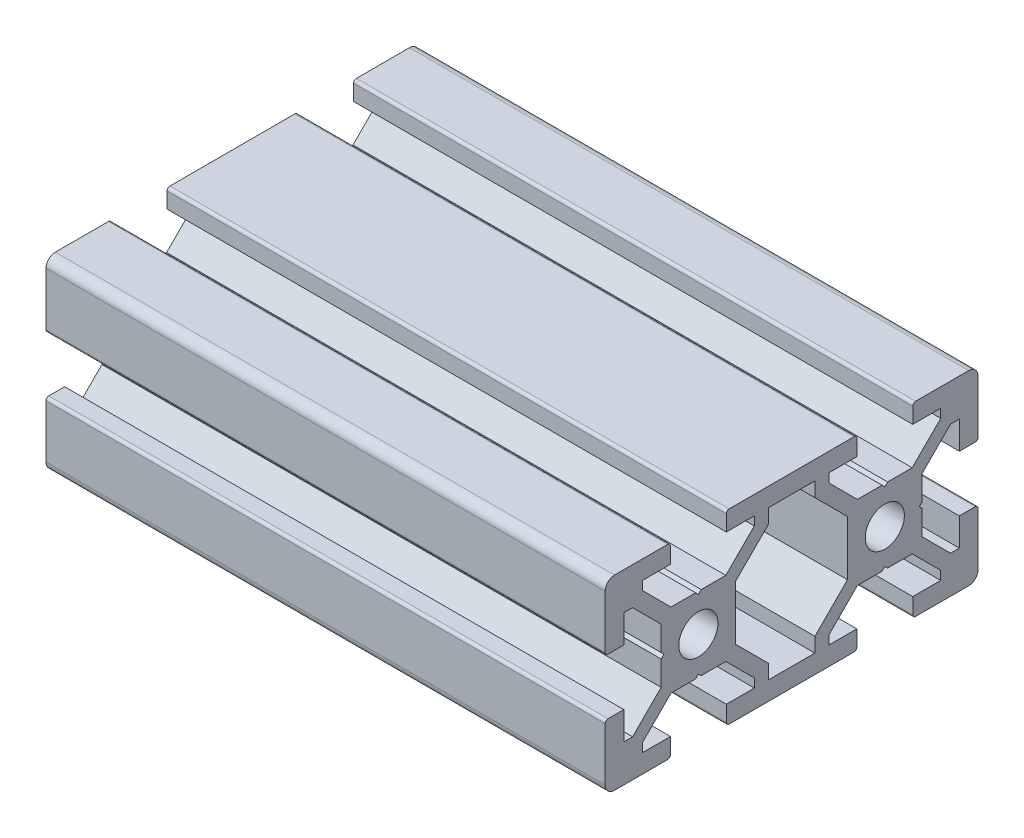
from build123d import *

# Parameters (mm, degrees)
SKETCH11_R               = 2.1
STRUCTURAL_MEMBER1_DEPTH = 60


with BuildPart() as part:
    # Sketch11 → Structural Member1 (new body)
    with BuildSketch(Plane.YZ.offset(-30)):
        with BuildLine():
            Line((-9, -20), (-3.3, -20))
            ThreePointArc((-3.3, -20), (-3.087867966, -19.912132034), (-3, -19.7))
            Line((-3, -19.7), (-3, -18))
            Line((-3, -18), (-6, -18))
            Line((-6, -18), (-6, -17.060660172))
            Line((-6, -17.060660172), (-2.939339828, -14))
            Line((-2.939339828, -14), (-0.3, -14))
            Line((-0.3, -14), (0, -13.7))
            Line((0, -13.7), (0.3, -14))
            Line((0.3, -14), (2.939339828, -14))
            Line((2.939339828, -14), (6, -17.060660172))
            Line((6, -17.060660172), (6, -18))
            Line((6, -18), (3, -18))
            Line((3, -18), (3, -19.7))
            ThreePointArc((3, -19.7), (3.087867966, -19.912132034), (3.3, -20))
            Line((3.3, -20), (9, -20))
            ThreePointArc((9, -20), (9.707106781, -19.707106781), (10, -19))
            Line((10, -19), (10, -13.3))
            ThreePointArc((10, -13.3), (9.912132034, -13.087867966), (9.7, -13))
            Line((9.7, -13), (8, -13))
            Line((8, -13), (8, -16))
            Line((8, -16), (7.060660172, -16))
            Line((7.060660172, -16), (4, -12.939339828))
            Line((4, -12.939339828), (4, -10.3))
            Line((4, -10.3), (3.7, -10))
            Line((3.7, -10), (4, -9.7))
            Line((4, -9.7), (4, -7.060660172))
            Line((4, -7.060660172), (7.060660172, -4))
            Line((7.060660172, -4), (8, -4))
            Line((8, -4), (8, -7))
            Line((8, -7), (9.7, -7))
            ThreePointArc((9.7, -7), (9.912132034, -6.912132034), (10, -6.7))
            Line((10, -6.7), (10, 6.7))
            ThreePointArc((10, 6.7), (9.912132034, 6.912132034), (9.7, 7))
            Line((9.7, 7), (8, 7))
            Line((8, 7), (8, 4))
            Line((8, 4), (7.060660172, 4))
            Line((7.060660172, 4), (4, 7.060660172))
            Line((4, 7.060660172), (4, 9.7))
            Line((4, 9.7), (3.7, 10))
            Line((3.7, 10), (4, 10.3))
            Line((4, 10.3), (4, 12.939339828))
            Line((4, 12.939339828), (7.060660172, 16))
            Line((7.060660172, 16), (8, 16))
            Line((8, 16), (8, 13))
            Line((8, 13), (9.7, 13))
            ThreePointArc((9.7, 13), (9.912132034, 13.087867966), (10, 13.3))
            Line((10, 13.3), (10, 19))
            ThreePointArc((10, 19), (9.707106781, 19.707106781), (9, 20))
            Line((9, 20), (3.3, 20))
            ThreePointArc((3.3, 20), (3.087867966, 19.912132034), (3, 19.7))
            Line((3, 19.7), (3, 18))
            Line((3, 18), (6, 18))
            Line((6, 18), (6, 17.060660172))
            Line((6, 17.060660172), (2.939339828, 14))
            Line((2.939339828, 14), (0.3, 14))
            Line((0.3, 14), (0, 13.7))
            Line((0, 13.7), (-0.3, 14))
            Line((-0.3, 14), (-2.939339828, 14))
            Line((-2.939339828, 14), (-6, 17.060660172))
            Line((-6, 17.060660172), (-6, 18))
            Line((-6, 18), (-3, 18))
            Line((-3, 18), (-3, 19.7))
            ThreePointArc((-3, 19.7), (-3.087867966, 19.912132034), (-3.3, 20))
            Line((-3.3, 20), (-9, 20))
            ThreePointArc((-9, 20), (-9.707106781, 19.707106781), (-10, 19))
            Line((-10, 19), (-10, 13.3))
            ThreePointArc((-10, 13.3), (-9.912132034, 13.087867966), (-9.7, 13))
            Line((-9.7, 13), (-8, 13))
            Line((-8, 13), (-8, 16))
            Line((-8, 16), (-7.060660172, 16))
            Line((-7.060660172, 16), (-4, 12.939339828))
            Line((-4, 12.939339828), (-4, 10.3))
            Line((-4, 10.3), (-3.7, 10))
            Line((-3.7, 10), (-4, 9.7))
            Line((-4, 9.7), (-4, 7.060660172))
            Line((-4, 7.060660172), (-7.060660172, 4))
            Line((-7.060660172, 4), (-8, 4))
            Line((-8, 4), (-8, 7))
            Line((-8, 7), (-9.7, 7))
            ThreePointArc((-9.7, 7), (-9.912132034, 6.912132034), (-10, 6.7))
            Line((-10, 6.7), (-10, -6.7))
            ThreePointArc((-10, -6.7), (-9.912132034, -6.912132034), (-9.7, -7))
            Line((-9.7, -7), (-8, -7))
            Line((-8, -7), (-8, -4))
            Line((-8, -4), (-7.060660172, -4))
            Line((-7.060660172, -4), (-4, -7.060660172))
            Line((-4, -7.060660172), (-4, -9.7))
            Line((-4, -9.7), (-3.7, -10))
            Line((-3.7, -10), (-4, -10.3))
            Line((-4, -10.3), (-4, -12.939339828))
            Line((-4, -12.939339828), (-7.060660172, -16))
            Line((-7.060660172, -16), (-8, -16))
            Line((-8, -16), (-8, -13))
            Line((-8, -13), (-9.7, -13))
            ThreePointArc((-9.7, -13), (-9.912132034, -13.087867966), (-10, -13.3))
            Line((-10, -13.3), (-10, -19))
            ThreePointArc((-10, -19), (-9.707106781, -19.707106781), (-9, -20))
        make_face()
        with Locations((0, 10)):
            Circle(SKETCH11_R, mode=Mode.SUBTRACT)
        with Locations((0, -10)):
            Circle(SKETCH11_R, mode=Mode.SUBTRACT)
        Polygon((-8, -2.5), (-6.439339828, -2.5), (-2.939339828, -6), (2.939339828, -6), (6.439339828, -2.5), (8, -2.5), (8, 2.5), (6.439339828, 2.5), (2.939339828, 6), (-2.939339828, 6), (-6.439339828, 2.5), (-8, 2.5), align=None, mode=Mode.SUBTRACT)
    extrude(amount=STRUCTURAL_MEMBER1_DEPTH)


solid = part.part
